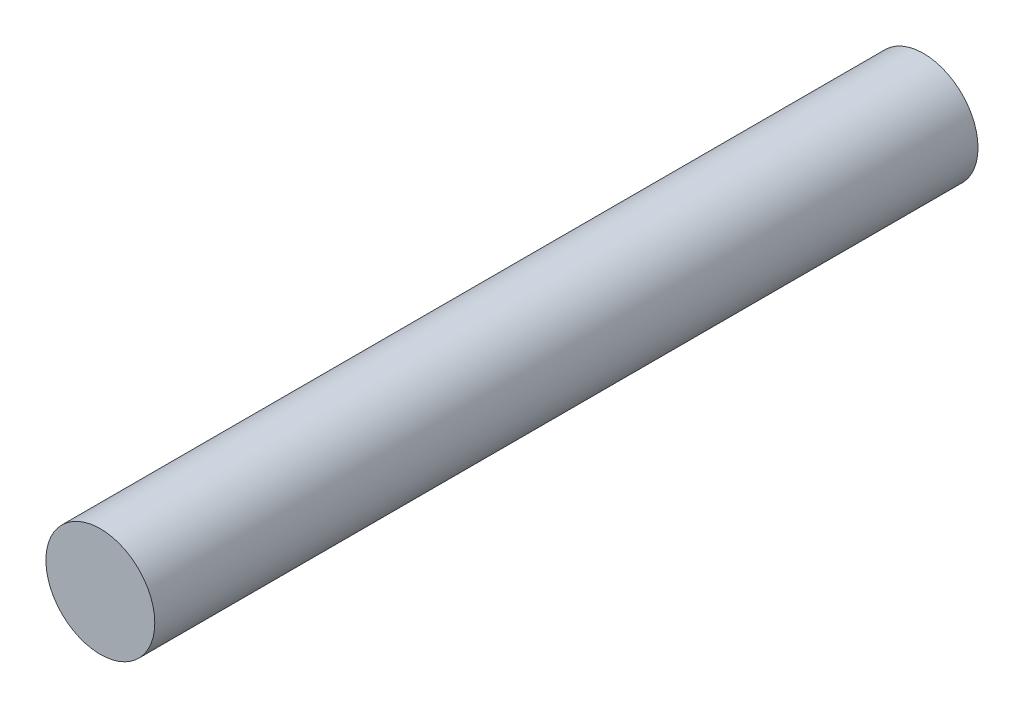
from build123d import *

# Parameters (mm, degrees)
SKETCH1_R           = 1.5
BOSS_EXTRUDE1_DEPTH = 22.68


with BuildPart() as part:
    # Sketch1 → Boss-Extrude1 (new body)
    with BuildSketch(Plane.XY):
        Circle(SKETCH1_R)
    extrude(amount=BOSS_EXTRUDE1_DEPTH)


solid = part.part
